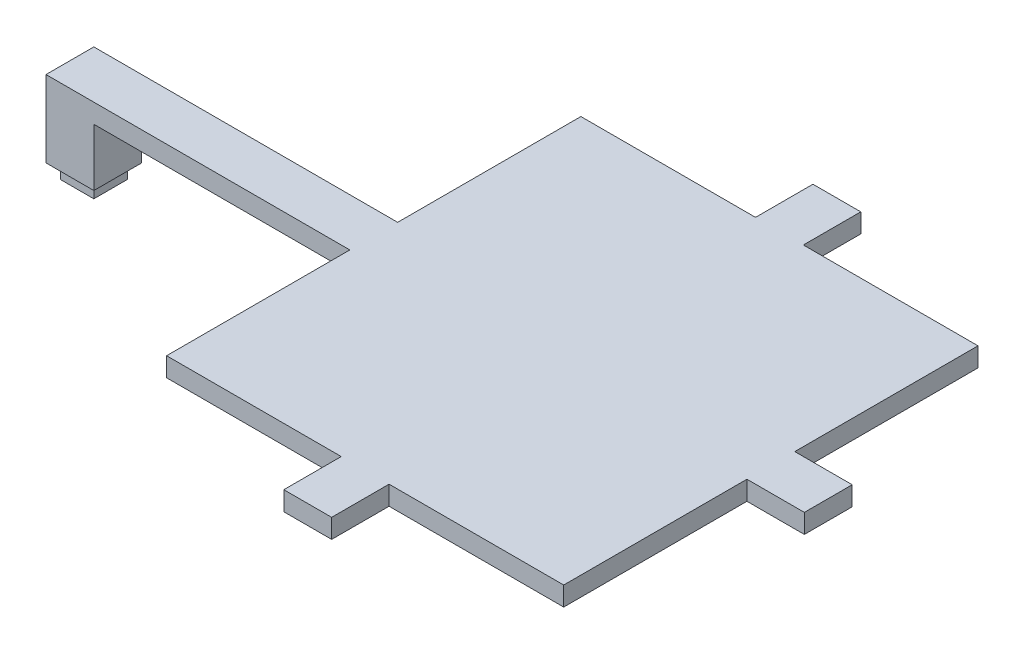
from build123d import *

# Parameters (mm, degrees)
SKETCH1_W           = 7
SKETCH1_H           = 7
BOSS_EXTRUDE1_DEPTH = 3
SKETCH3_W           = 10
SKETCH3_H           = 10
BOSS_EXTRUDE2_DEPTH = 12
BOSS_EXTRUDE4_DEPTH = 4
SKETCH7_W           = 10
SKETCH7_H           = 10
BOSS_EXTRUDE6_DEPTH = 4
SKETCH8_W           = 10
SKETCH8_H           = 4
BOSS_EXTRUDE7_DEPTH = 53.5


with BuildPart() as part:
    # Sketch1 → Boss-Extrude1 (new body)
    with BuildSketch(Plane(origin=(0, 0, 0), x_dir=(1, 0, 0), z_dir=(0, 1, 0))):
        Rectangle(SKETCH1_W, SKETCH1_H)
    extrude(amount=BOSS_EXTRUDE1_DEPTH)

    # Sketch3 → Boss-Extrude2 (add)
    with BuildSketch(Plane(origin=(0, 3, 0), x_dir=(1, 0, 0), z_dir=(0, 1, 0))):
        Rectangle(SKETCH3_W, SKETCH3_H)
    extrude(amount=BOSS_EXTRUDE2_DEPTH)

    # Sketch7 → Boss-Extrude6 (add)
    with BuildSketch(Plane(origin=(0, 15, 0), x_dir=(1, 0, 0), z_dir=(0, 1, 0))):
        Rectangle(SKETCH7_W, SKETCH7_H)
    extrude(amount=BOSS_EXTRUDE6_DEPTH)



with BuildPart() as body_2:
    # Sketch4 → Boss-Extrude4 (new body)
    with BuildSketch(Plane(origin=(0, 15, 0), x_dir=(1, 0, 0), z_dir=(0, 1, 0))):
        Polygon((105, 43.294473551), (105, 55.294473551), (95, 55.294473551), (95, 43.294473551), (58.5, 43.294473551), (58.5, -43.294473551), (95, -43.294473551), (95, -55.294473551), (105, -55.294473551), (105, -43.294473551), (141.5, -43.294473551), (141.5, -5), (153.5, -5), (153.5, 5), (141.5, 5), (141.5, 43.294473551), align=None)
    extrude(amount=BOSS_EXTRUDE4_DEPTH)


with BuildPart() as part_1:
    add(part.part)

    add(body_2.part)  # Boss-Extrude7 merges body 2
    # Sketch8 → Boss-Extrude7 (add)
    with BuildSketch(Plane(origin=(5, 0, 0), x_dir=(0, 0, -1), z_dir=(1, 0, 0))):
        with Locations((0, 17)):
            Rectangle(SKETCH8_W, SKETCH8_H)
    extrude(amount=BOSS_EXTRUDE7_DEPTH)


solid = part_1.part
